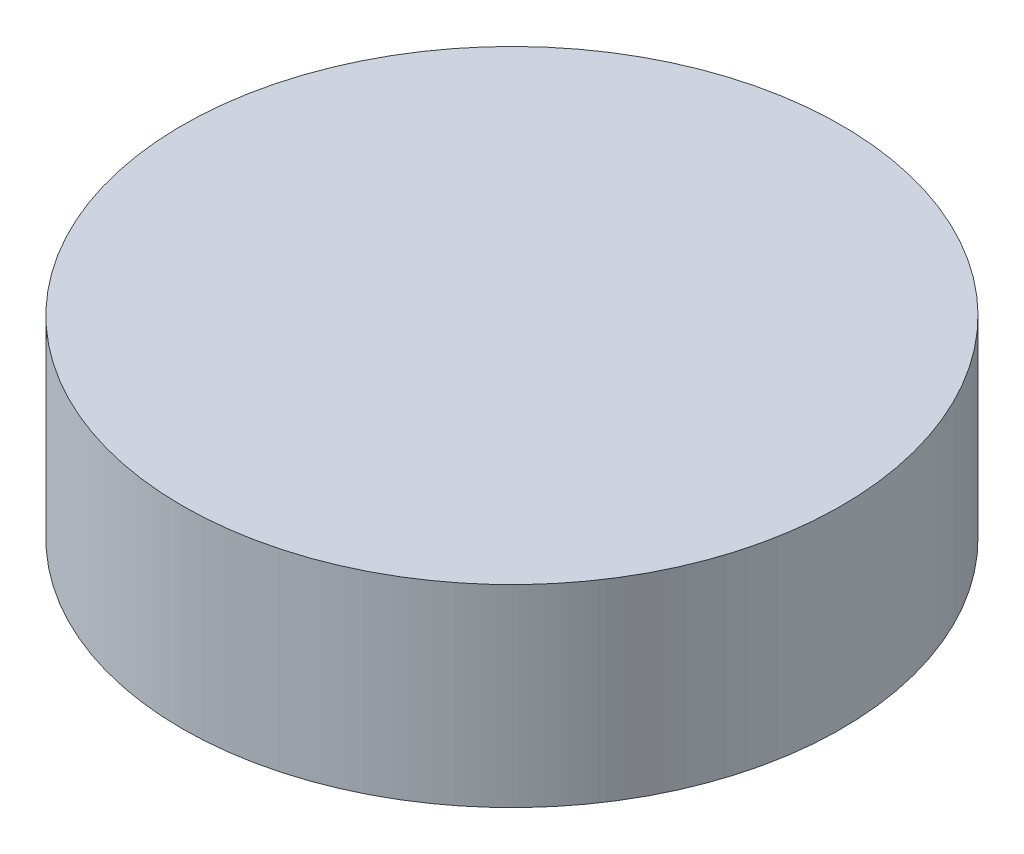
from build123d import *

# Parameters (mm, degrees)
SKETCH2_R           = 5
BOSS_EXTRUDE1_DEPTH = 2.93


with BuildPart() as part:
    # Sketch2 → Boss-Extrude1 (new body)
    with BuildSketch(Plane(origin=(0, 0, 0), x_dir=(1, 0, 0), z_dir=(0, 1, 0))):
        Circle(SKETCH2_R)
    extrude(amount=BOSS_EXTRUDE1_DEPTH)


solid = part.part
